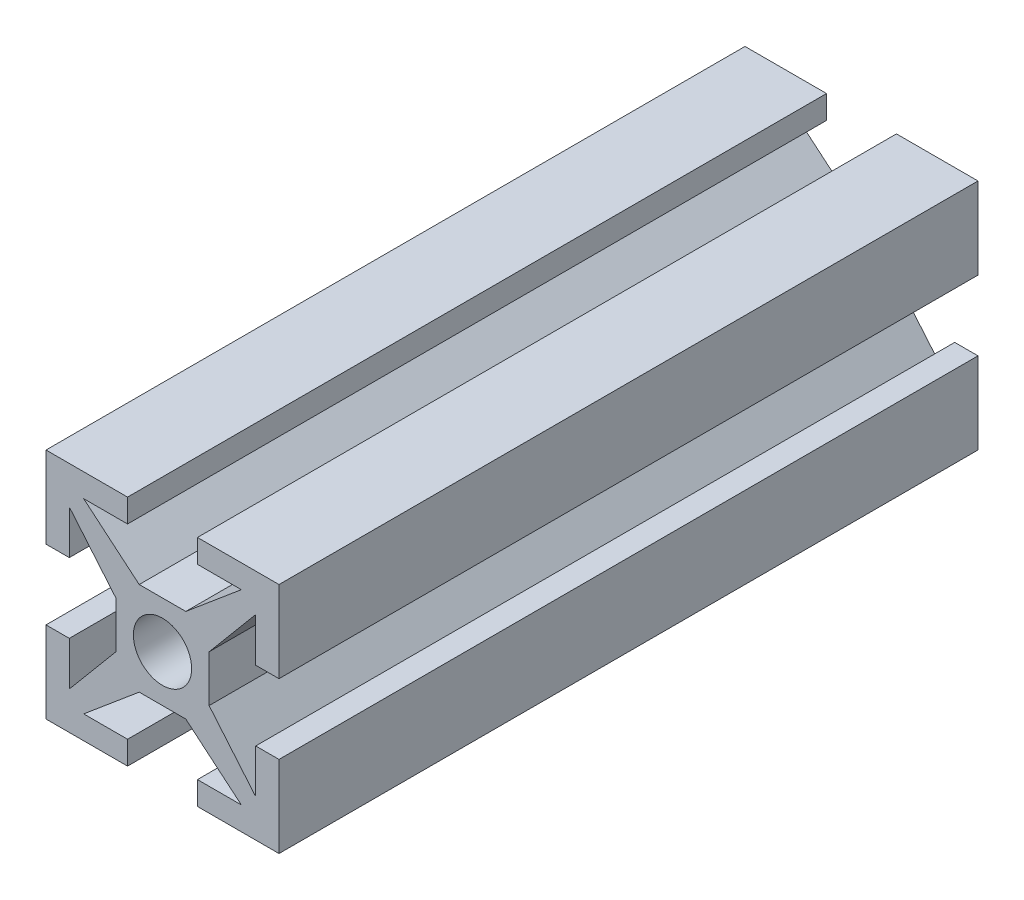
from build123d import *

# Parameters (mm, degrees)
ESQUISSE2_R          = 1.25
MAIN_EXTRUSION_DEPTH = 30


with BuildPart() as part:
    # Esquisse2 → Main Extrusion (new body)
    with BuildSketch(Plane.XY):
        Polygon((-1, -2), (1, -2), (3.383507185, -4), (1.5, -4), (1.5, -5), (5, -5), (5, -1.5), (4, -1.5), (4, -3.383507185), (2, -1), (2, 1), (4, 3.383507185), (4, 1.5), (5, 1.5), (5, 5), (1.5, 5), (1.5, 4), (3.383507185, 4), (1, 2), (-1, 2), (-3.383507185, 4), (-1.5, 4), (-1.5, 5), (-5, 5), (-5, 1.5), (-4, 1.5), (-4, 3.383507185), (-2, 1), (-2, -1), (-4, -3.383507185), (-4, -1.5), (-5, -1.5), (-5, -5), (-1.5, -5), (-1.5, -4), (-3.383507185, -4), align=None)
        Circle(ESQUISSE2_R, mode=Mode.SUBTRACT)
    extrude(amount=MAIN_EXTRUSION_DEPTH)


solid = part.part
